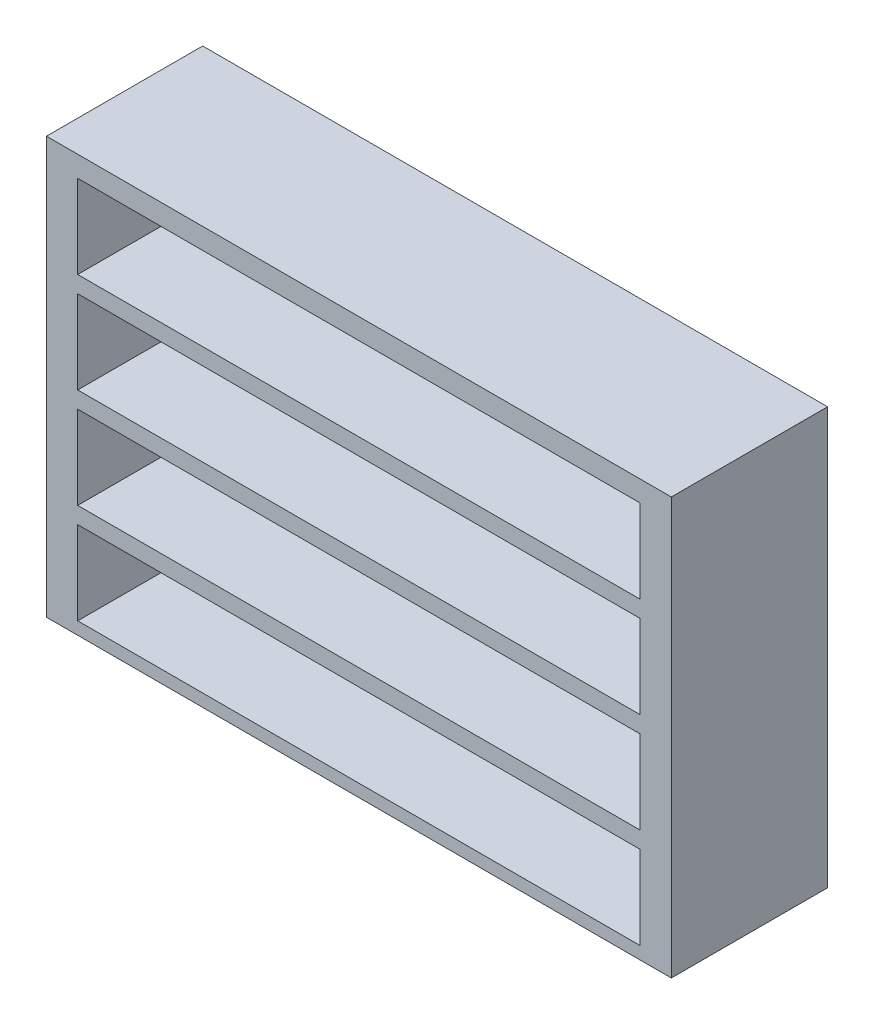
from build123d import *

# Parameters (mm, degrees)
SKETCH1_W           = 3000
SKETCH1_H           = 2000
BOSS_EXTRUDE1_DEPTH = 750
SKETCH2_W           = 2700
SKETCH2_H           = 400
CUT_EXTRUDE1_DEPTH  = 725
LPATTERN1_COUNT     = 4
LPATTERN1_PITCH     = 480


with BuildPart() as part:
    # Sketch1 → Boss-Extrude1 (new body)
    with BuildSketch(Plane.XY):
        Rectangle(SKETCH1_W, SKETCH1_H)
    extrude(amount=BOSS_EXTRUDE1_DEPTH)

    # Sketch2 → Cut-Extrude1 (cut)
    with BuildSketch(Plane.XY.offset(750)):
        with Locations((0, 700)):
            Rectangle(SKETCH2_W, SKETCH2_H)
    cut_extrude1 = extrude(amount=-CUT_EXTRUDE1_DEPTH, mode=Mode.SUBTRACT)

    # LPattern1: Cut-Extrude1 ×4
    with Locations(*[(0, -i * LPATTERN1_PITCH, 0) for i in range(1, LPATTERN1_COUNT)]):
        add(cut_extrude1, mode=Mode.SUBTRACT)


solid = part.part
